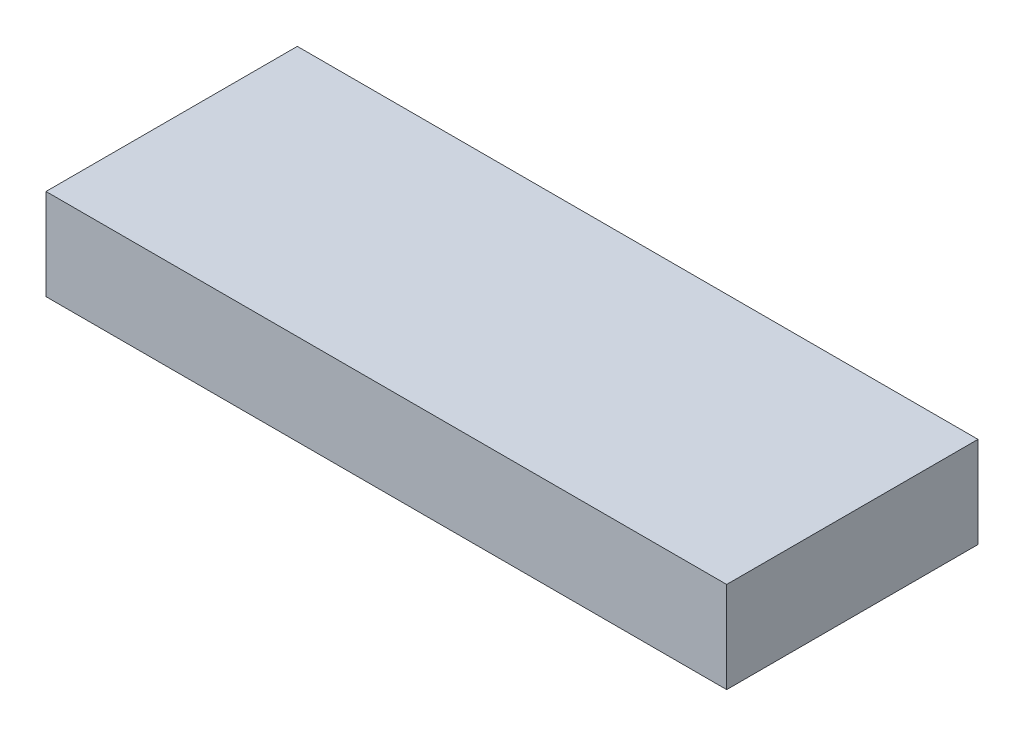
from build123d import *

# Parameters (mm, degrees)
SKETCH1_W           = 32.5
SKETCH1_H           = 12
BOSS_EXTRUDE1_DEPTH = 4.35


with BuildPart() as part:
    # Sketch1 → Boss-Extrude1 (new body)
    with BuildSketch(Plane(origin=(0, 0, 0), x_dir=(1, 0, 0), z_dir=(0, 1, 0))):
        Rectangle(SKETCH1_W, SKETCH1_H)
    extrude(amount=BOSS_EXTRUDE1_DEPTH)


solid = part.part
